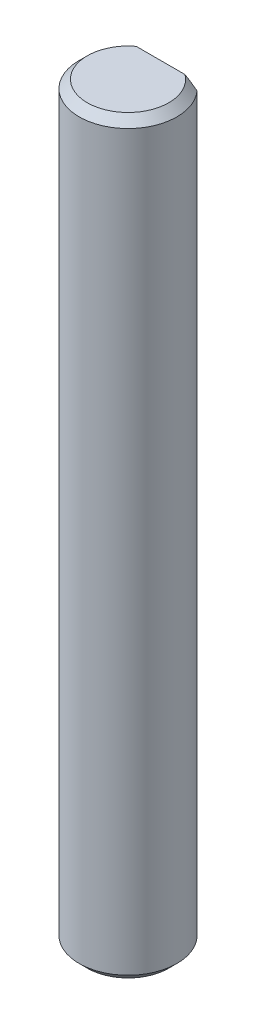
from build123d import *

# Parameters (mm, degrees)
SKETCH1_R           = 3
BOSS_EXTRUDE1_DEPTH = 46
CHAMFER1_SIZE       = 0.5
CUT_EXTRUDE1_DEPTH  = 6
CUT_EXTRUDE2_DEPTH  = 6


with BuildPart() as part:
    # Sketch1 → Boss-Extrude1 (new body)
    with BuildSketch(Plane(origin=(0, 0, 0), x_dir=(1, 0, 0), z_dir=(0, 1, 0))):
        Circle(SKETCH1_R)
    extrude(amount=BOSS_EXTRUDE1_DEPTH)

    # Chamfer1
    chamfer1_edges = [part.edges().sort_by_distance(p)[0] for p in [
        (-3, 0, 0),
        (-3, 46, 0),
    ]]
    chamfer(chamfer1_edges, length=CHAMFER1_SIZE)

    # Sketch2 → Cut-Extrude1 (cut)
    with BuildSketch(Plane(origin=(0, 46, 0), x_dir=(1, 0, 0), z_dir=(0, 1, 0))):
        with BuildLine():
            Line((-2.236067977, 2), (2.236067977, 2))
            ThreePointArc((2.236067977, 2), (0, 3), (-2.236067977, 2))
        make_face()
    extrude(amount=-CUT_EXTRUDE1_DEPTH, mode=Mode.SUBTRACT)

    # Sketch3 → Cut-Extrude2 (cut)
    with BuildSketch(Plane.XZ):
        with BuildLine():
            Line((2.236067977, -2), (-2.236067977, -2))
            ThreePointArc((-2.236067977, -2), (0, -3), (2.236067977, -2))
        make_face()
    extrude(amount=-CUT_EXTRUDE2_DEPTH, mode=Mode.SUBTRACT)


solid = part.part
